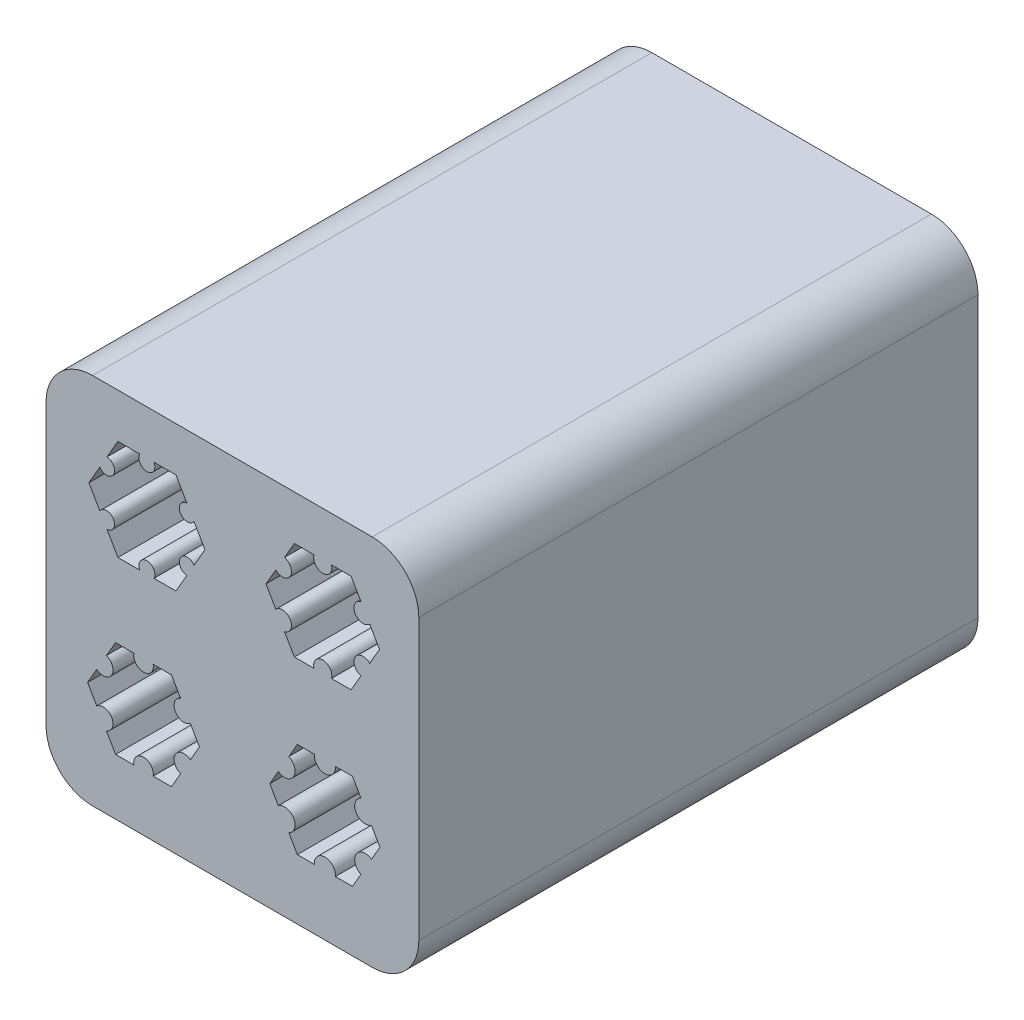
from build123d import *

# Parameters (mm, degrees)
SKETCH1_W               = 50.8
SKETCH1_H               = 50.8
BOSS_EXTRUDE1_DEPTH     = 76.2
CUT_EXTRUDE_THIN1_DEPTH = 76.2
CUT_EXTRUDE_THIN3_DEPTH = 76.2
CUT_EXTRUDE_THIN4_DEPTH = 76.2
CUT_EXTRUDE_THIN5_DEPTH = 76.2
FILLET1_R               = 6.35


with BuildPart() as part:
    # Sketch1 → Boss-Extrude1 (new body)
    with BuildSketch(Plane.XY):
        Rectangle(SKETCH1_W, SKETCH1_H)
    extrude(amount=BOSS_EXTRUDE1_DEPTH)

    # Sketch3 → Cut-Extrude-Thin1 (cut)
    with BuildSketch(Plane.XY.offset(76.2)):
        with BuildLine():
            Line((-12.612425978, 5.645622006), (-15.601534006, 5.645622006))
            Line((-15.601534006, 5.645622006), (-17.096088177, 8.234265403))
            ThreePointArc((-17.096088177, 8.234265403), (-16.204143595, 9.864371952), (-18.061829574, 9.906978335))
            Line((-18.061829574, 9.906978335), (-19.556383755, 12.495621749))
            Line((-19.556383755, 12.495621749), (-18.061829888, 15.084265344))
            ThreePointArc((-18.061829888, 15.084265344), (-16.204143914, 15.126871952), (-17.096088694, 16.756978394))
            Line((-17.096088694, 16.756978394), (-15.601534816, 19.345622006))
            Line((-15.601534816, 19.345622006), (-12.612426748, 19.345622006))
            ThreePointArc((-12.612426748, 19.345622006), (-11.646685452, 17.758122006), (-10.680944156, 19.345622006))
            Line((-10.680944156, 19.345622006), (-7.691836108, 19.345622006))
            Line((-7.691836108, 19.345622006), (-6.197282084, 16.756978502))
            ThreePointArc((-6.197282084, 16.756978502), (-7.08922655, 15.126871634), (-5.231540325, 15.084266234))
            Line((-5.231540325, 15.084266234), (-3.736985995, 12.495622199))
            Line((-3.736985995, 12.495622199), (-5.231540019, 9.906978694))
            ThreePointArc((-5.231540019, 9.906978694), (-7.089225995, 9.864372199), (-6.197281314, 8.234265703))
            Line((-6.197281314, 8.234265703), (-7.691835339, 5.645622199))
            Line((-7.691835339, 5.645622199), (-10.680943287, 5.645622199))
            ThreePointArc((-10.680943287, 5.645622199), (-11.646684791, 7.233122006), (-12.612425978, 5.645622006))
        make_face()
        with BuildLine():
            Line((-13.234184683, 6.145622006), (-15.312858892, 6.145622006))
            Line((-15.312858892, 6.145622006), (-16.352196106, 7.945806615))
            ThreePointArc((-16.352196106, 7.945806615), (-15.771130909, 10.114371978), (-17.939696272, 10.695437176))
            Line((-17.939696272, 10.695437176), (-18.979033486, 12.495621784))
            Line((-18.979033486, 12.495621784), (-17.93969649, 14.295806519))
            ThreePointArc((-17.93969649, 14.295806519), (-15.771131197, 14.876871978), (-16.352196657, 17.045437272))
            Line((-16.352196657, 17.045437272), (-15.312859661, 18.845622006))
            Line((-15.312859661, 18.845622006), (-13.234185452, 18.845622006))
            ThreePointArc((-13.234185452, 18.845622006), (-11.646685452, 17.258122006), (-10.059185452, 18.845622006))
            Line((-10.059185452, 18.845622006), (-7.980511243, 18.845622006))
            Line((-7.980511243, 18.845622006), (-6.941174138, 17.045437335))
            ThreePointArc((-6.941174138, 17.045437335), (-7.522239276, 14.876871676), (-5.353673478, 14.295807059))
            Line((-5.353673478, 14.295807059), (-4.314336264, 12.495622199))
            Line((-4.314336264, 12.495622199), (-5.353673369, 10.695437527))
            ThreePointArc((-5.353673369, 10.695437527), (-7.522238697, 10.114372199), (-6.941173369, 7.94580687))
            Line((-6.941173369, 7.94580687), (-7.980510473, 6.145622199))
            Line((-7.980510473, 6.145622199), (-10.059184683, 6.145622199))
            ThreePointArc((-10.059184683, 6.145622199), (-11.646684779, 7.733122006), (-13.234184683, 6.145622006))
        make_face(mode=Mode.SUBTRACT)
    extrude(amount=-CUT_EXTRUDE_THIN1_DEPTH, mode=Mode.SUBTRACT)


with BuildPart() as body_2:
    # of the pieces the cut leaves, the one that is kept (cut_extrude_thin1_keep)
    add(part.part.solids().sort_by_distance((-25.4, 25.4, 0))[0])

    # Sketch8 → Cut-Extrude-Thin3 (cut)
    with BuildSketch(Plane.XY.offset(76.2)):
        with BuildLine():
            Line((11.124642482, 5.92120821), (8.443369261, 5.92120821))
            Line((8.443369261, 5.92120821), (7.102732509, 8.243258853))
            ThreePointArc((7.102732509, 8.243258853), (7.884060943, 10.064958164), (5.915758817, 10.299157308))
            Line((5.915758817, 10.299157308), (4.575122058, 12.621207963))
            Line((4.575122058, 12.621207963), (5.915758536, 14.943258781))
            ThreePointArc((5.915758536, 14.943258781), (7.884060634, 15.177458164), (7.102731978, 16.99915738))
            Line((7.102731978, 16.99915738), (8.443368463, 19.32120821))
            Line((8.443368463, 19.32120821), (11.124641713, 19.32120821))
            ThreePointArc((11.124641713, 19.32120821), (12.311615281, 17.73370821), (13.498588848, 19.32120821))
            Line((13.498588848, 19.32120821), (16.179862084, 19.32120821))
            Line((16.179862084, 19.32120821), (17.520498702, 16.999157473))
            ThreePointArc((17.520498702, 16.999157473), (16.739170356, 15.177457866), (18.707472818, 14.943259523))
            Line((18.707472818, 14.943259523), (20.048109657, 12.621208402))
            Line((20.048109657, 12.621208402), (18.707473039, 10.299157665))
            ThreePointArc((18.707473039, 10.299157665), (16.739170927, 10.064958402), (17.520499472, 8.243259139))
            Line((17.520499472, 8.243259139), (16.179862854, 5.921208402))
            Line((16.179862854, 5.921208402), (13.498589674, 5.921208402))
            ThreePointArc((13.498589674, 5.921208402), (12.31161595, 7.50870821), (11.124642482, 5.92120821))
        make_face()
        with BuildLine():
            Line((10.72411605, 6.27120821), (8.645441841, 6.27120821))
            Line((8.645441841, 6.27120821), (7.606104627, 8.071392818))
            ThreePointArc((7.606104627, 8.071392818), (8.187169824, 10.239958182), (6.01860446, 10.821023379))
            Line((6.01860446, 10.821023379), (4.979267247, 12.621207988))
            Line((4.979267247, 12.621207988), (6.018604242, 14.421392722))
            ThreePointArc((6.018604242, 14.421392722), (8.187169536, 15.002458182), (7.606104076, 17.171023475))
            Line((7.606104076, 17.171023475), (8.645441071, 18.97120821))
            Line((8.645441071, 18.97120821), (10.724115281, 18.97120821))
            ThreePointArc((10.724115281, 18.97120821), (12.311615281, 17.38370821), (13.899115281, 18.97120821))
            Line((13.899115281, 18.97120821), (15.97778949, 18.97120821))
            Line((15.97778949, 18.97120821), (17.017126595, 17.171023538))
            ThreePointArc((17.017126595, 17.171023538), (16.436061457, 15.00245788), (18.604627255, 14.421393263))
            Line((18.604627255, 14.421393263), (19.643964469, 12.621208402))
            Line((19.643964469, 12.621208402), (18.604627364, 10.821023731))
            ThreePointArc((18.604627364, 10.821023731), (16.436062036, 10.239958402), (17.017127364, 8.071393074))
            Line((17.017127364, 8.071393074), (15.977790259, 6.271208402))
            Line((15.977790259, 6.271208402), (13.89911605, 6.271208402))
            ThreePointArc((13.89911605, 6.271208402), (12.311615954, 7.85870821), (10.72411605, 6.27120821))
        make_face(mode=Mode.SUBTRACT)
    extrude(amount=-CUT_EXTRUDE_THIN3_DEPTH, mode=Mode.SUBTRACT)


with BuildPart() as body_2_2:
    # of the pieces the cut leaves, the one that is kept (cut_extrude_thin3_keep)
    add(body_2.part.solids().sort_by_distance((-25.4, 25.4, 0))[0])

    # Sketch7 → Cut-Extrude-Thin4 (cut)
    with BuildSketch(Plane.XY.offset(76.2)):
        with BuildLine():
            Line((-13.424079874, -17.756295509), (-15.920663846, -17.756295509))
            Line((-15.920663846, -17.756295509), (-17.168955962, -15.594190442))
            ThreePointArc((-17.168955962, -15.594190442), (-16.451104648, -13.662545549), (-18.482883895, -13.318400823))
            Line((-18.482883895, -13.318400823), (-19.731176017, -11.156295748))
            Line((-19.731176017, -11.156295748), (-18.482884157, -8.994190522))
            ThreePointArc((-18.482884157, -8.994190522), (-16.451104952, -8.650045549), (-17.1689565, -6.718400744))
            Line((-17.1689565, -6.718400744), (-15.920664635, -4.556295509))
            Line((-15.920664635, -4.556295509), (-13.424080643, -4.556295509))
            ThreePointArc((-13.424080643, -4.556295509), (-12.110152848, -6.143795509), (-10.796225054, -4.556295509))
            Line((-10.796225054, -4.556295509), (-8.299641072, -4.556295509))
            Line((-8.299641072, -4.556295509), (-7.051349081, -6.71840066))
            ThreePointArc((-7.051349081, -6.71840066), (-7.769200318, -8.650045845), (-5.737420698, -8.994189851))
            Line((-5.737420698, -8.994189851), (-4.489128526, -11.156295316))
            Line((-4.489128526, -11.156295316), (-5.737420517, -13.318400467))
            ThreePointArc((-5.737420517, -13.318400467), (-7.769199743, -13.662545316), (-7.051348312, -15.594190165))
            Line((-7.051348312, -15.594190165), (-8.299640302, -17.756295316))
            Line((-8.299640302, -17.756295316), (-10.796224248, -17.756295316))
            ThreePointArc((-10.796224248, -17.756295316), (-12.110152177, -16.168795509), (-13.424079874, -17.756295509))
        make_face()
        with BuildLine():
            Line((-13.697652079, -17.506295509), (-15.776326288, -17.506295509))
            Line((-15.776326288, -17.506295509), (-16.815663502, -15.7061109))
            ThreePointArc((-16.815663502, -15.7061109), (-16.234598305, -13.537545536), (-18.403163669, -12.956480339))
            Line((-18.403163669, -12.956480339), (-19.442500882, -11.156295731))
            Line((-19.442500882, -11.156295731), (-18.403163887, -9.356110996))
            ThreePointArc((-18.403163887, -9.356110996), (-16.234598594, -8.775045536), (-16.815664053, -6.606480243))
            Line((-16.815664053, -6.606480243), (-15.776327058, -4.806295509))
            Line((-15.776327058, -4.806295509), (-13.697652848, -4.806295509))
            ThreePointArc((-13.697652848, -4.806295509), (-12.110152848, -6.393795509), (-10.522652848, -4.806295509))
            Line((-10.522652848, -4.806295509), (-8.443978639, -4.806295509))
            Line((-8.443978639, -4.806295509), (-7.404641534, -6.60648018))
            ThreePointArc((-7.404641534, -6.60648018), (-7.985706672, -8.775045839), (-5.817140874, -9.356110456))
            Line((-5.817140874, -9.356110456), (-4.77780366, -11.156295316))
            Line((-4.77780366, -11.156295316), (-5.817140765, -12.956479988))
            ThreePointArc((-5.817140765, -12.956479988), (-7.985706094, -13.537545316), (-7.404640765, -15.706110645))
            Line((-7.404640765, -15.706110645), (-8.44397787, -17.506295316))
            Line((-8.44397787, -17.506295316), (-10.522652079, -17.506295316))
            ThreePointArc((-10.522652079, -17.506295316), (-12.110152175, -15.918795509), (-13.697652079, -17.506295509))
        make_face(mode=Mode.SUBTRACT)
    extrude(amount=-CUT_EXTRUDE_THIN4_DEPTH, mode=Mode.SUBTRACT)


with BuildPart() as body_2_3:
    # of the pieces the cut leaves, the one that is kept (cut_extrude_thin4_keep)
    add(body_2_2.part.solids().sort_by_distance((-25.4, 25.4, 0))[0])

    # Sketch9 → Cut-Extrude-Thin5 (cut)
    with BuildSketch(Plane.XY.offset(76.2)):
        with BuildLine():
            Line((11.173933507, -17.190560255), (8.850809256, -17.190560255))
            Line((8.850809256, -17.190560255), (7.689247009, -15.178675708))
            ThreePointArc((7.689247009, -15.178675708), (8.349235968, -13.146810291), (6.259594366, -12.70244504))
            Line((6.259594366, -12.70244504), (5.098032116, -10.690560488))
            Line((5.098032116, -10.690560488), (6.259594122, -8.678675795))
            ThreePointArc((6.259594122, -8.678675795), (8.34923567, -8.234310291), (7.689246465, -6.202444953))
            Line((7.689246465, -6.202444953), (8.850808475, -4.190560255))
            Line((8.850808475, -4.190560255), (11.173932738, -4.190560255))
            ThreePointArc((11.173932738, -4.190560255), (12.60358523, -5.778060255), (14.033237723, -4.190560255))
            Line((14.033237723, -4.190560255), (16.35636198, -4.190560255))
            Line((16.35636198, -4.190560255), (17.517924109, -6.202444878))
            ThreePointArc((17.517924109, -6.202444878), (16.857935218, -8.234310587), (18.947577222, -8.678675182))
            Line((18.947577222, -8.678675182), (20.109139499, -10.690560063))
            Line((20.109139499, -10.690560063), (18.947577371, -12.702444685))
            ThreePointArc((18.947577371, -12.702444685), (16.857935796, -13.146810063), (17.517924878, -15.17867544))
            Line((17.517924878, -15.17867544), (16.35636275, -17.190560063))
            Line((16.35636275, -17.190560063), (14.033238513, -17.190560063))
            ThreePointArc((14.033238513, -17.190560063), (12.603585903, -15.603060255), (11.173933507, -17.190560255))
        make_face()
        with BuildLine():
            Line((11.016086, -17.040560255), (8.93741179, -17.040560255))
            Line((8.93741179, -17.040560255), (7.898074577, -15.240375647))
            ThreePointArc((7.898074577, -15.240375647), (8.479139774, -13.071810283), (6.31057441, -12.490745086))
            Line((6.31057441, -12.490745086), (5.271237196, -10.690560477))
            Line((5.271237196, -10.690560477), (6.310574192, -8.890375743))
            ThreePointArc((6.310574192, -8.890375743), (8.479139485, -8.309310283), (7.898074025, -6.14074499))
            Line((7.898074025, -6.14074499), (8.937411021, -4.340560255))
            Line((8.937411021, -4.340560255), (11.01608523, -4.340560255))
            ThreePointArc((11.01608523, -4.340560255), (12.60358523, -5.928060255), (14.19108523, -4.340560255))
            Line((14.19108523, -4.340560255), (16.26975944, -4.340560255))
            Line((16.26975944, -4.340560255), (17.309096544, -6.140744927))
            ThreePointArc((17.309096544, -6.140744927), (16.728031407, -8.309310585), (18.896597205, -8.890375202))
            Line((18.896597205, -8.890375202), (19.935934418, -10.690560063))
            Line((19.935934418, -10.690560063), (18.896597314, -12.490744734))
            ThreePointArc((18.896597314, -12.490744734), (16.728031985, -13.071810063), (17.309097314, -15.240375391))
            Line((17.309097314, -15.240375391), (16.269760209, -17.040560063))
            Line((16.269760209, -17.040560063), (14.191086, -17.040560063))
            ThreePointArc((14.191086, -17.040560063), (12.603585904, -15.453060255), (11.016086, -17.040560255))
        make_face(mode=Mode.SUBTRACT)
    extrude(amount=-CUT_EXTRUDE_THIN5_DEPTH, mode=Mode.SUBTRACT)


with BuildPart() as body_2_4:
    # of the pieces the cut leaves, the one that is kept (cut_extrude_thin5_keep)
    add(body_2_3.part.solids().sort_by_distance((-25.4, 25.4, 0))[0])

    # Fillet1
    fillet1_edges = [body_2_4.edges().sort_by_distance(p)[0] for p in [
        (25.4, -25.4, 38.1),
        (25.4, 25.4, 38.1),
        (-25.4, 25.4, 38.1),
        (-25.4, -25.4, 38.1),
    ]]
    fillet(fillet1_edges, radius=FILLET1_R)


solid = body_2_4.part
